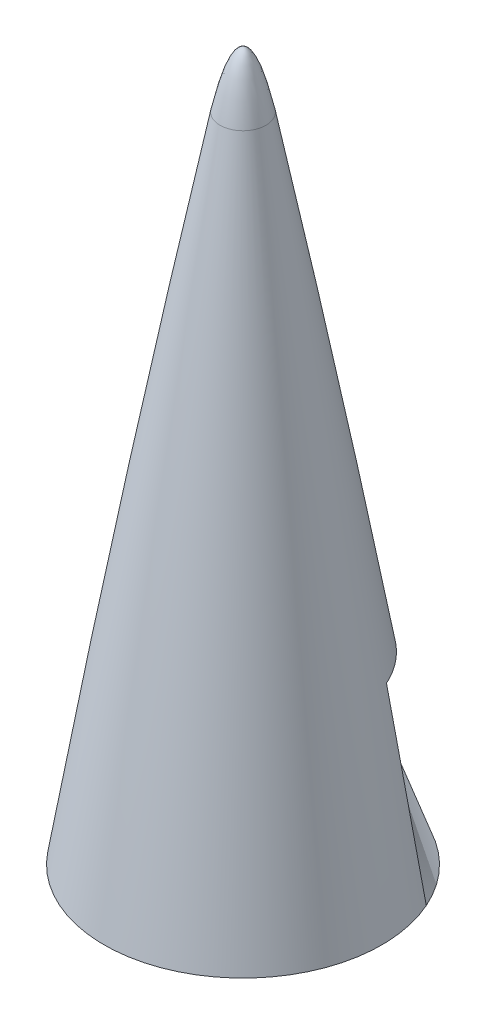
from build123d import *


with BuildPart() as part:
    # Sketch1 → Revolve1 (revolve)
    with BuildSketch(Plane.XY):
        with BuildLine():
            Line((0, 812.8), (-36.810738243, 812.8))
            ThreePointArc((-36.810738243, 812.8), (-19.427786081, 914.585216157), (0, 1016))
            Line((0, 1016), (0, 812.8))
        make_face()
    revolve(axis=Axis((0, 1016, 0), (0, -1, 0)))

    # Sketch2 → Cut-Revolve1 (revolve, cut)
    with BuildSketch(Plane(origin=(0, 0, 0), x_dir=(0, 0, -1), z_dir=(1, 0, 0))):
        with BuildLine():
            Line((8.737841343, 985.45781512), (8.103051438, 1019.178629525))
            Line((8.103051438, 1019.178629525), (0, 1019.178629525))
            Line((0, 1019.178629525), (0, 1000.322478733))
            add(Edge.make_bspline(
                [(6.07372986, 985.45781512), (3.013196655, 1000.338691952), (0, 1000.322478733)],
                knots=[0, 0, 0, 0.50046116, 0.50046116, 0.50046116], degree=2))
            Line((6.07372986, 985.45781512), (8.737841343, 985.45781512))
        make_face()
    revolve(axis=Axis((0, 985.45781512, 0), (0, 1, 0)), mode=Mode.SUBTRACT)


solid = part.part
